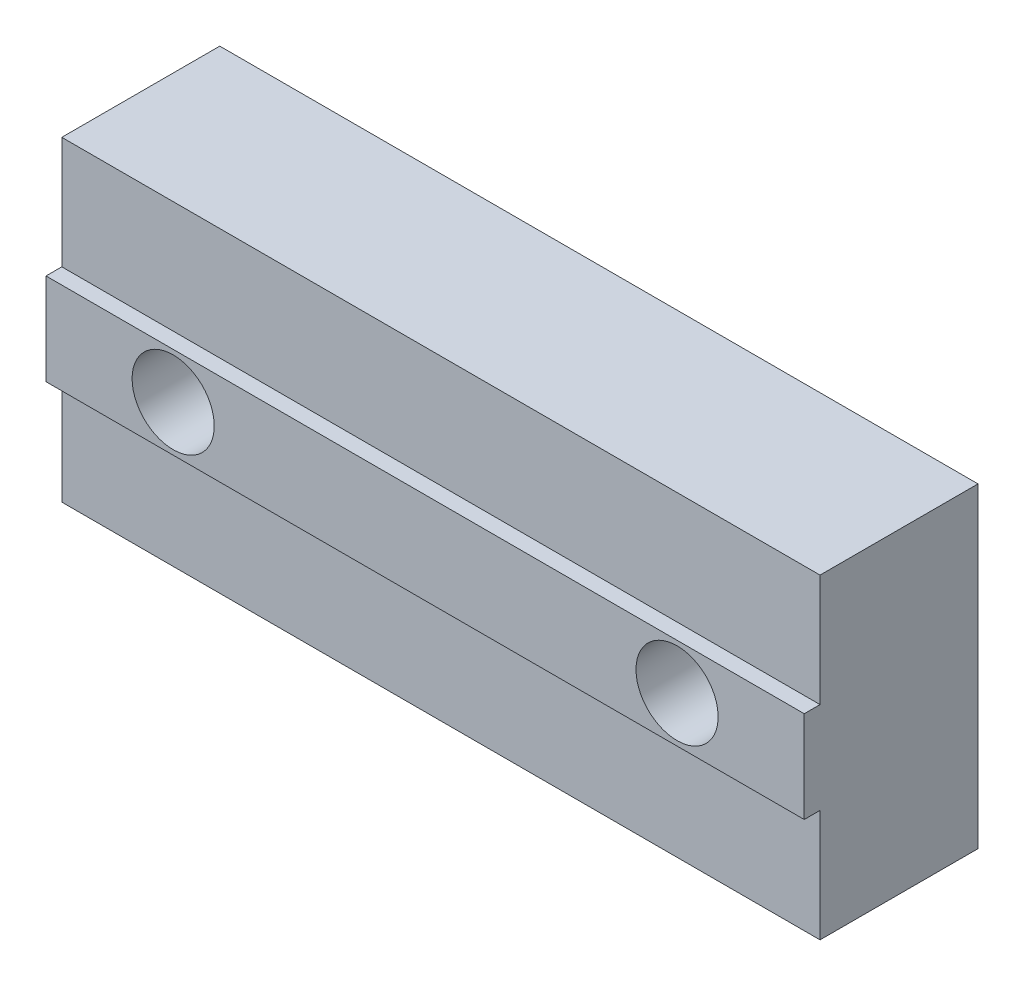
from build123d import *

# Parameters (mm, degrees)
SKETCH1_W           = 48
SKETCH1_H           = 20
BOSS_EXTRUDE1_DEPTH = 10
SKETCH4_W           = 48
SKETCH4_H           = 5.8
BOSS_EXTRUDE2_DEPTH = 1
SKETCH2_R           = 2.6
CUT_EXTRUDE1_DEPTH  = 12


with BuildPart() as part:
    # Sketch1 → Boss-Extrude1 (new body)
    with BuildSketch(Plane.XY):
        Rectangle(SKETCH1_W, SKETCH1_H)
    extrude(amount=BOSS_EXTRUDE1_DEPTH)

    # Sketch4 → Boss-Extrude2 (add)
    with BuildSketch(Plane.XY.offset(10)):
        Rectangle(SKETCH4_W, SKETCH4_H)
    extrude(amount=BOSS_EXTRUDE2_DEPTH)

    # Sketch2 → Cut-Extrude1 (cut, through all)
    with BuildSketch(Plane.XY):
        with Locations((-15.95, 0)):
            Circle(SKETCH2_R)
    cut_extrude1 = extrude(amount=CUT_EXTRUDE1_DEPTH, mode=Mode.SUBTRACT)

    # Mirror1: Cut-Extrude1 across plane
    add(cut_extrude1.mirror(Plane(origin=(0, 0, 0), x_dir=(0, 0, 1), z_dir=(1, 0, 0))), mode=Mode.SUBTRACT)


solid = part.part
